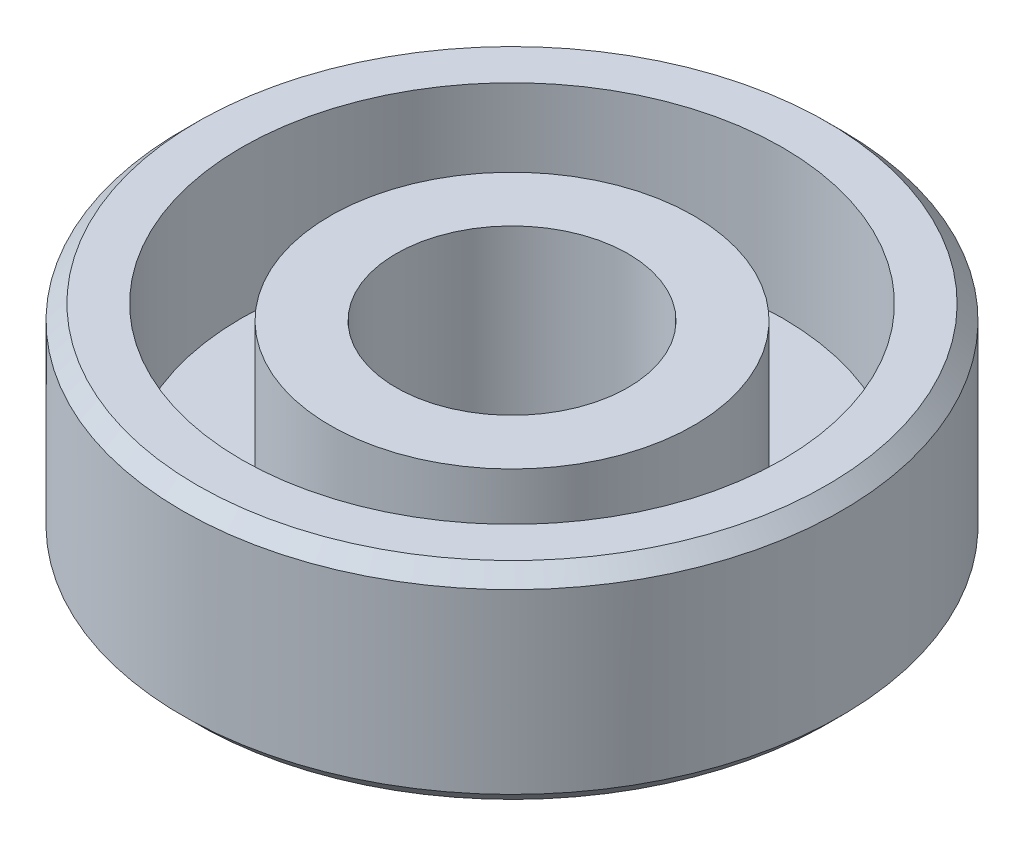
from build123d import *

# Parameters (mm, degrees)
CHAMFER1_SIZE = 0.5


with BuildPart() as part:
    # Sketch1 → Revolve1 (revolve)
    with BuildSketch(Plane.XY):
        Polygon((3.925, 17.592522397), (6.15, 17.592522397), (6.15, 13.092522397), (9.15, 13.092522397), (9.15, 18.092522397), (11.15, 18.092522397), (11.15, 11.092522397), (9.662817283, 11.092522397), (3.925, 11.092522397), align=None)
    revolve(axis=Axis((0, 0, 0), (0, 1, 0)))

    # Chamfer1
    chamfer1_edges = [part.edges().sort_by_distance(p)[0] for p in [
        (-11.15, 18.092522397, 0),
        (-11.15, 11.092522397, 0),
    ]]
    chamfer(chamfer1_edges, length=CHAMFER1_SIZE)


solid = part.part
